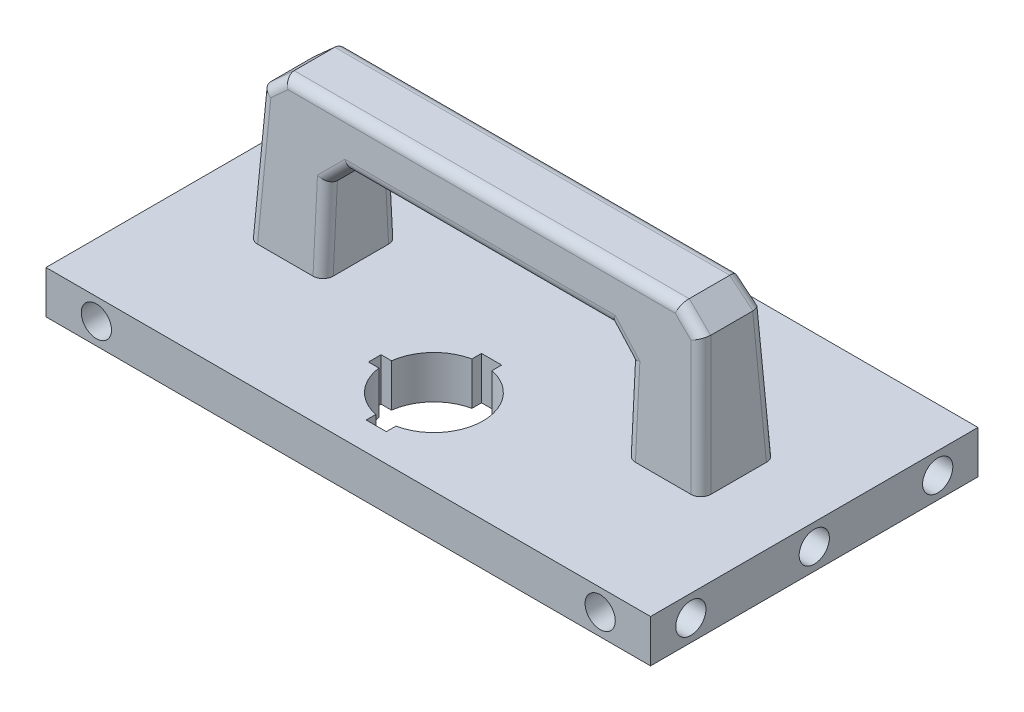
from build123d import *

# Parameters (mm, degrees)
SKETCH1_W                                      = 65
SKETCH1_H                                      = 8.5
BOSS_EXTRUDE1_DEPTH                            = 120
F_6_0MM_DOWEL_HOLE1_AT_2_COUNT                 = 2
F_6_0MM_DOWEL_HOLE1_AT_2_PITCH                 = 24.5
F_6_0MM_DOWEL_HOLE1_AT_3_COUNT                 = 2
F_6_0MM_DOWEL_HOLE1_AT_3_PITCH                 = 49
SKETCH4_W                                      = 90
SKETCH4_H                                      = 15
BOSS_EXTRUDE2_DEPTH                            = 30
BOSS_EXTRUDE2_TAPER                            = 3
SKETCH5_W                                      = 60
SKETCH5_H                                      = 20
CUT_EXTRUDE1_DEPTH                             = 33.5
CUT_EXTRUDE1_DEPTH_BACK                        = 33.5
CHAMFER1_SIZE2                                 = 4
CHAMFER1_SIZE                                  = 4.227018011
CHAMFER1_EDGE_2_SIZE2                          = 4
CHAMFER1_EDGE_2_SIZE                           = 4.227018011
CHAMFER1_EDGE_3_SIZE                           = 4
CHAMFER1_EDGE_4_SIZE                           = 4
FILLET1_R                                      = 2
F_6_0MM_DOWEL_HOLE2_AT_2_COUNT                 = 2
F_6_0MM_DOWEL_HOLE2_AT_2_PITCH                 = 100
CSK_FOR_M4_FLAT_HEAD_MACHINE_SCREW1_AT_2_COUNT = 2
CSK_FOR_M4_FLAT_HEAD_MACHINE_SCREW1_AT_2_PITCH = 75.00274093
CUT_EXTRUDE2_DEPTH                             = 9.5


with BuildPart() as part:
    # Sketch1 → Boss-Extrude1 (new body)
    with BuildSketch(Plane(origin=(0, 0, 0), x_dir=(0, 0, -1), z_dir=(1, 0, 0))):
        Rectangle(SKETCH1_W, SKETCH1_H)
    extrude(amount=BOSS_EXTRUDE1_DEPTH)

    # Sketch3 → Ø6.0mm Dowel Hole1 (revolve, cut)
    with BuildSketch(Plane(origin=(120, 0, 24.5), x_dir=(0, 0, -1), z_dir=(0, 1, 0))):
        Polygon((0, 0), (0, 11.802581857), (3, 10), (3, 0), align=None)
    f_6_0mm_dowel_hole1 = revolve(axis=Axis((126.35, 0, 24.5), (-1, 0, 0)), mode=Mode.SUBTRACT)

    # Ø6.0mm Dowel Hole1 at 2: Ø6.0mm Dowel Hole1 ×2
    with Locations(*[(0, 0, -i * F_6_0MM_DOWEL_HOLE1_AT_2_PITCH) for i in range(1, F_6_0MM_DOWEL_HOLE1_AT_2_COUNT)]):
        add(f_6_0mm_dowel_hole1, mode=Mode.SUBTRACT)

    # Ø6.0mm Dowel Hole1 at 3: Ø6.0mm Dowel Hole1 ×2
    with Locations(*[(0, 0, -i * F_6_0MM_DOWEL_HOLE1_AT_3_PITCH) for i in range(1, F_6_0MM_DOWEL_HOLE1_AT_3_COUNT)]):
        add(f_6_0mm_dowel_hole1, mode=Mode.SUBTRACT)

    # Mirror1: Ø6.0mm Dowel Hole1 across plane
    add(f_6_0mm_dowel_hole1.mirror(Plane(origin=(60, 0, 0), x_dir=(0, 0, 1), z_dir=(1, 0, 0))), mode=Mode.SUBTRACT)

    # Mirror1 copy 1 sketch → Mirror1 copy 1 (revolve, cut)
    with BuildSketch(Plane(origin=(0, 0, 0), x_dir=(0, 0, -1), z_dir=(0, 1, 0))):
        Polygon((0, 0), (0, -11.802581857), (3, -10), (3, 0), align=None)
    revolve(axis=Axis((-6.35, 0, 0), (-1, 0, 0)), mode=Mode.SUBTRACT)

    # Mirror1 copy 2 sketch → Mirror1 copy 2 (revolve, cut)
    with BuildSketch(Plane(origin=(0, 0, -24.5), x_dir=(0, 0, -1), z_dir=(0, 1, 0))):
        Polygon((0, 0), (0, -11.802581857), (3, -10), (3, 0), align=None)
    revolve(axis=Axis((-6.35, 0, -24.5), (-1, 0, 0)), mode=Mode.SUBTRACT)

    # Sketch4 → Boss-Extrude2 (add)
    with BuildSketch(Plane(origin=(0, 4.25, 0), x_dir=(1, 0, 0), z_dir=(0, 1, 0))):
        with Locations((60, 0)):
            Rectangle(SKETCH4_W, SKETCH4_H)
    extrude(amount=BOSS_EXTRUDE2_DEPTH, taper=BOSS_EXTRUDE2_TAPER)

    # Sketch5 → Cut-Extrude1 (cut, two sides)
    with BuildSketch(Plane.XY) as cut_extrude1_sk:
        with Locations((60, 14.25)):
            Rectangle(SKETCH5_W, SKETCH5_H)
    extrude(amount=CUT_EXTRUDE1_DEPTH, mode=Mode.SUBTRACT)
    extrude(cut_extrude1_sk.sketch, amount=-CUT_EXTRUDE1_DEPTH_BACK, mode=Mode.SUBTRACT)

    # Chamfer1
    chamfer1_edges = [part.edges().sort_by_distance(p)[0] for p in [
        (16.572233378, 34.25, 0),
    ]]
    chamfer(chamfer1_edges, length=CHAMFER1_SIZE, length2=CHAMFER1_SIZE2)

    # Chamfer1 edge 2
    chamfer1_edge_2_edges = [part.edges().sort_by_distance(p)[0] for p in [
        (103.427766622, 34.25, 0),
    ]]
    chamfer(chamfer1_edge_2_edges, length=CHAMFER1_EDGE_2_SIZE, length2=CHAMFER1_EDGE_2_SIZE2)

    # Chamfer1 edge 3
    chamfer1_edge_3_edges = [part.edges().sort_by_distance(p)[0] for p in [
        (30, 24.25, 0),
    ]]
    chamfer(chamfer1_edge_3_edges, length=CHAMFER1_EDGE_3_SIZE)

    # Chamfer1 edge 4
    chamfer1_edge_4_edges = [part.edges().sort_by_distance(p)[0] for p in [
        (90, 24.25, 0),
    ]]
    chamfer(chamfer1_edge_4_edges, length=CHAMFER1_EDGE_4_SIZE)

    # Fillet1
    fillet1_edges = [part.edges().sort_by_distance(p)[0] for p in [
        (104.318555223, 17.25274093, 6.818555223),
        (15.681444777, 17.25274093, 6.818555223),
        (18.581070471, 32.25274093, 6.032438534),
        (101.418929529, 32.25274093, 6.032438534),
        (32, 22.25, 6.556659973),
        (32, 22.25, -6.556659973),
        (88, 22.25, 6.556659973),
        (88, 22.25, -6.556659973),
        (90, 12.25, -7.080737766),
        (30, 12.25, -7.080737766),
        (30, 12.25, 7.080737766),
        (60, 24.25, -6.451844414),
        (60, 24.25, 6.451844414),
        (90, 12.25, 7.080737766),
        (60, 34.25, 5.927766622),
        (60, 34.25, -5.927766622),
        (15.681444777, 17.25274093, -6.818555223),
        (104.318555223, 17.25274093, -6.818555223),
        (18.581070471, 32.25274093, -6.032438534),
        (101.418929529, 32.25274093, -6.032438534),
    ]]
    fillet(fillet1_edges, radius=FILLET1_R)

    # Sketch7 → Ø6.0mm Dowel Hole2 (revolve, cut)
    with BuildSketch(Plane(origin=(110, 0, -32.5), x_dir=(0, 1, 0), z_dir=(1, 0, 0))):
        Polygon((0, 0), (0, 9.802581857), (3, 8), (3, 0), align=None)
    f_6_0mm_dowel_hole2 = revolve(axis=Axis((110, 0, -38.85), (0, 0, 1)), mode=Mode.SUBTRACT)

    # Ø6.0mm Dowel Hole2 at 2: Ø6.0mm Dowel Hole2 ×2
    with Locations(*[(-i * F_6_0MM_DOWEL_HOLE2_AT_2_PITCH, 0, 0) for i in range(1, F_6_0MM_DOWEL_HOLE2_AT_2_COUNT)]):
        add(f_6_0mm_dowel_hole2, mode=Mode.SUBTRACT)

    # Mirror2: Ø6.0mm Dowel Hole2 across plane
    add(f_6_0mm_dowel_hole2.mirror(Plane.XY), mode=Mode.SUBTRACT)

    # Mirror2 copy 1 sketch → Mirror2 copy 1 (revolve, cut)
    with BuildSketch(Plane(origin=(10, 0, 32.5), x_dir=(0, 1, 0), z_dir=(1, 0, 0))):
        Polygon((0, 0), (0, -9.802581857), (3, -8), (3, 0), align=None)
    revolve(axis=Axis((10, 0, 38.85), (0, 0, 1)), mode=Mode.SUBTRACT)


with BuildPart() as body_2:
    # Split1: the piece on the far side of the plane
    add(part.part)
    split(bisect_by=Plane.ZX.offset(4.25), keep=Keep.BOTTOM)


with BuildPart() as part_1:
    add(part.part)

    # Split1
    split(bisect_by=Plane.ZX.offset(4.25), keep=Keep.TOP)


with BuildPart() as csk_for_m4_flat_head_machine_screw1_tool:
    # Sketch9 → CSK for M4 Flat Head Machine Screw1 (revolve)
    with BuildSketch(Plane(origin=(97.501370465, -4.25, 0), x_dir=(0, 0, -1), z_dir=(1, 0, 0))):
        Polygon((0, 0), (0, 21.442065486), (2.4, 20), (2.4, 2.3), (4.7, 0), align=None)
    csk_for_m4_flat_head_machine_screw1 = revolve(axis=Axis((97.501370465, -10.6, 0), (0, 1, 0)))


with BuildPart() as part_2:
    add(part_1.part)

    # CSK for M4 Flat Head Machine Screw1: cut by csk_for_m4_flat_head_machine_screw1_tool
    add(csk_for_m4_flat_head_machine_screw1_tool.part, mode=Mode.SUBTRACT)


with BuildPart() as body_2_1:
    add(body_2.part)

    # CSK for M4 Flat Head Machine Screw1: cut by csk_for_m4_flat_head_machine_screw1_tool
    add(csk_for_m4_flat_head_machine_screw1_tool.part, mode=Mode.SUBTRACT)


with BuildPart() as csk_for_m4_flat_head_machine_screw1_at_2_tool:
    # CSK for M4 Flat Head Machine Screw1 at 2: CSK for M4 Flat Head Machine Screw1 ×2
    with Locations(*[(-i * CSK_FOR_M4_FLAT_HEAD_MACHINE_SCREW1_AT_2_PITCH, 0, 0) for i in range(1, CSK_FOR_M4_FLAT_HEAD_MACHINE_SCREW1_AT_2_COUNT)]):
        add(csk_for_m4_flat_head_machine_screw1)


with BuildPart() as part_3:
    add(part_2.part)

    # CSK for M4 Flat Head Machine Screw1 at 2: cut by csk_for_m4_flat_head_machine_screw1_at_2_tool
    add(csk_for_m4_flat_head_machine_screw1_at_2_tool.part, mode=Mode.SUBTRACT)


with BuildPart() as body_2_2:
    add(body_2_1.part)

    # CSK for M4 Flat Head Machine Screw1 at 2: cut by csk_for_m4_flat_head_machine_screw1_at_2_tool
    add(csk_for_m4_flat_head_machine_screw1_at_2_tool.part, mode=Mode.SUBTRACT)

    # Sketch10 → Cut-Extrude2 (cut, through all)
    with BuildSketch(Plane(origin=(0, 4.25, 0), x_dir=(1, 0, 0), z_dir=(0, 1, 0))):
        with BuildLine():
            Line((48.25, -14.25), (48.25, -16.75))
            Line((48.25, -16.75), (50.330460197, -16.75))
            ThreePointArc((50.330460197, -16.75), (50.25, -15.5), (50.330460197, -14.25))
            Line((50.330460197, -14.25), (48.25, -14.25))
        make_face()
        with BuildLine():
            Line((52.25, -16.75), (50.330460197, -16.75))
            ThreePointArc((50.330460197, -16.75), (52.84202384, -22.120111577), (58, -25.042667342))
            Line((58, -25.042667342), (58, -23.55))
            Line((58, -23.55), (62, -23.55))
            Line((62, -23.55), (62, -25.042667342))
            ThreePointArc((62, -25.042667342), (67.568437752, -21.646645427), (69.75, -15.5))
            ThreePointArc((69.75, -15.5), (67.568437752, -9.353354573), (62, -5.957332658))
            Line((62, -5.957332658), (62, -7.45))
            Line((62, -7.45), (58, -7.45))
            Line((58, -7.45), (58, -5.957332658))
            ThreePointArc((58, -5.957332658), (52.84202384, -8.879888423), (50.330460197, -14.25))
            Line((50.330460197, -14.25), (52.25, -14.25))
            Line((52.25, -14.25), (52.25, -16.75))
        make_face()
        with BuildLine():
            Line((58, -23.55), (58, -25.042667342))
            ThreePointArc((58, -25.042667342), (60, -25.25), (62, -25.042667342))
            Line((62, -25.042667342), (62, -23.55))
            Line((62, -23.55), (58, -23.55))
        make_face()
        with BuildLine():
            ThreePointArc((62, -25.042667342), (60, -25.25), (58, -25.042667342))
            Line((58, -25.042667342), (58, -26.95))
            Line((58, -26.95), (62, -26.95))
            Line((62, -26.95), (62, -25.042667342))
        make_face()
        with BuildLine():
            ThreePointArc((50.330460197, -14.25), (50.25, -15.5), (50.330460197, -16.75))
            Line((50.330460197, -16.75), (52.25, -16.75))
            Line((52.25, -16.75), (52.25, -14.25))
            Line((52.25, -14.25), (50.330460197, -14.25))
        make_face()
        with BuildLine():
            Line((58, -4.05), (58, -5.957332658))
            ThreePointArc((58, -5.957332658), (60, -5.75), (62, -5.957332658))
            Line((62, -5.957332658), (62, -4.05))
            Line((62, -4.05), (58, -4.05))
        make_face()
        with BuildLine():
            ThreePointArc((62, -5.957332658), (60, -5.75), (58, -5.957332658))
            Line((58, -5.957332658), (58, -7.45))
            Line((58, -7.45), (62, -7.45))
            Line((62, -7.45), (62, -5.957332658))
        make_face()
    extrude(amount=-CUT_EXTRUDE2_DEPTH, mode=Mode.SUBTRACT)


solid = Compound([part_3.part, body_2_2.part])
